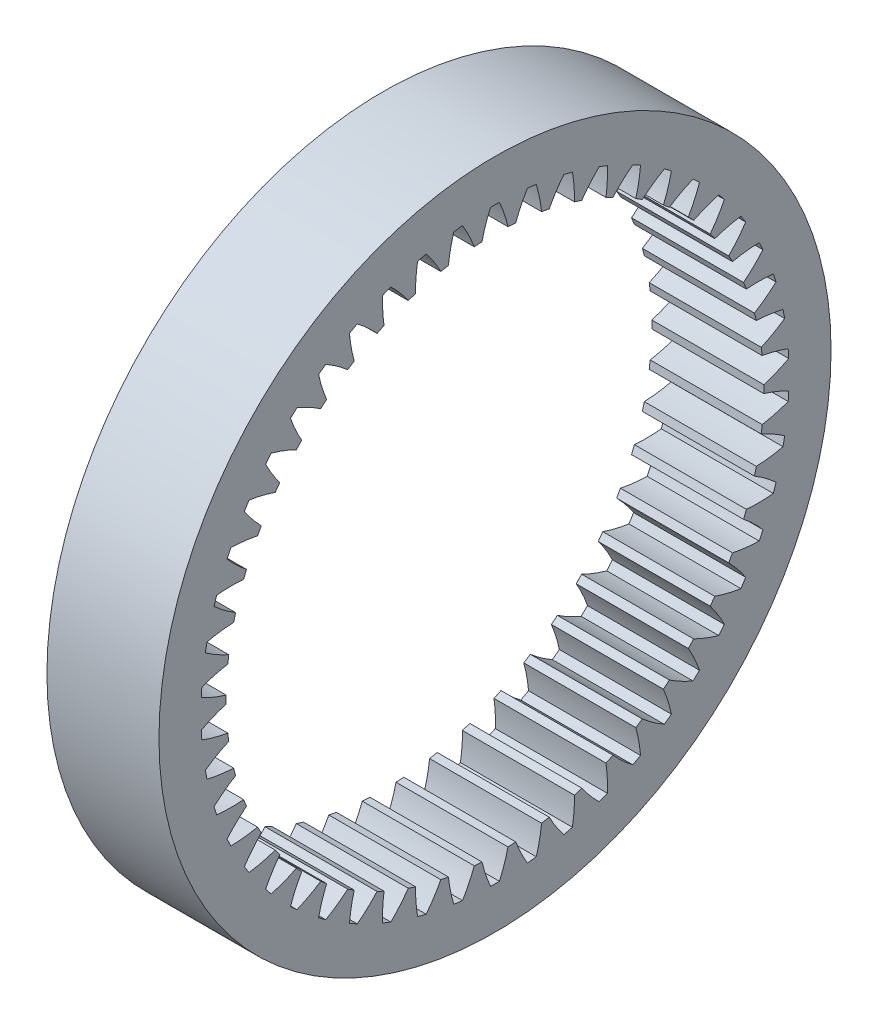
from build123d import *

# Parameters (mm, degrees)
BASPROSKE_W     = 10
BASPROSKE_H     = 6
TOOTHCUT_DEPTH  = 44.588989435
TEETHCUTS_COUNT = 50
TEETHCUTS_ANGLE = 352.8


with BuildPart() as part:
    # BasProSke → Base-Revolve (revolve)
    with BuildSketch(Plane(origin=(0, 0, 0), x_dir=(1, 0, 0), z_dir=(0, 1, 0))):
        with Locations((5, 27)):
            Rectangle(BASPROSKE_W, BASPROSKE_H)
    revolve(axis=Axis((-10, 0, 0), (1, 0, 0)))

    # TooCutSke → ToothCut (cut, through all)
    with BuildSketch(Plane(origin=(0, 0, 0), x_dir=(0, 0, -1), z_dir=(1, 0, 0))):
        with BuildLine():
            ThreePointArc((1.167705051, 23.946146038), (0.83690396, 25.115926791), (0.394037849, 26.248042502))
            ThreePointArc((0.394037849, 26.248042502), (0, 26.251), (-0.394037849, 26.248042502))
            ThreePointArc((-0.394037849, 26.248042502), (-0.83690396, 25.115926791), (-1.167705051, 23.946146038))
            ThreePointArc((-1.167705051, 23.946146038), (0, 23.9746), (1.167705051, 23.946146038))
        make_face()
    toothcut = extrude(amount=TOOTHCUT_DEPTH, mode=Mode.SUBTRACT)

    # TeethCuts: ToothCut ×50 about axis
    teethcuts_axis = Axis((-10, 0, 0), (1, 0, 0))
    for i in range(1, TEETHCUTS_COUNT):
        add(toothcut.rotate(teethcuts_axis, i * TEETHCUTS_ANGLE / (TEETHCUTS_COUNT - 1)), mode=Mode.SUBTRACT)


solid = part.part
